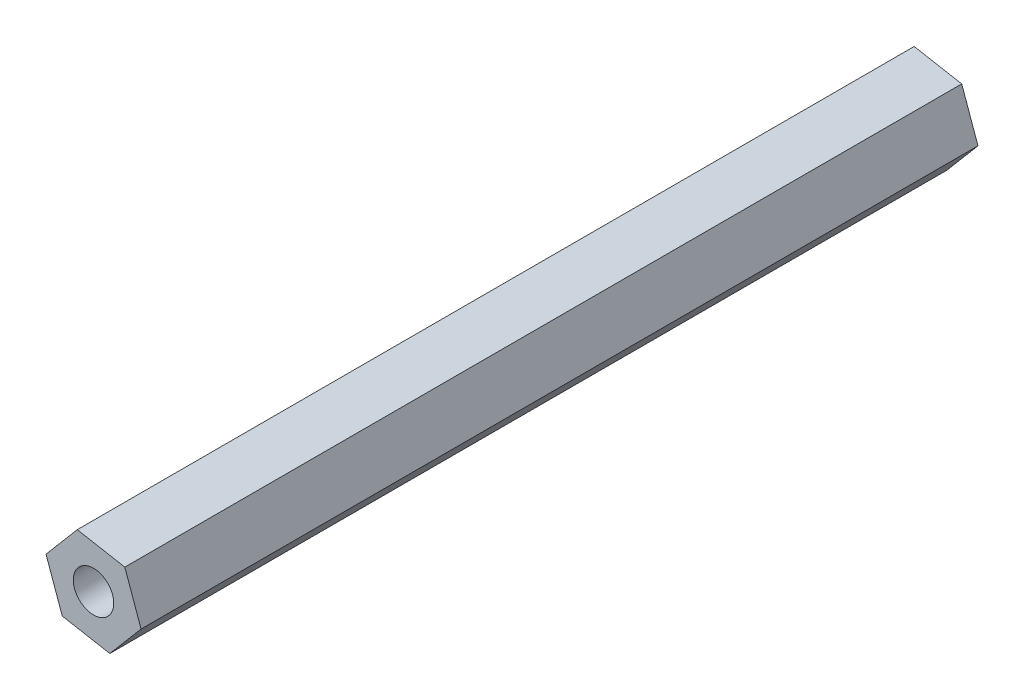
from build123d import *

# Parameters (mm, degrees)
RESSALTO_EXTRUS_O1_DEPTH = 60
ESBO_O4_R                = 1.45
CORTE_EXTRUS_O2_DEPTH    = 61


with BuildPart() as part:
    # Esboço1 → Ressalto-extrusão1 (new body)
    with BuildSketch(Plane.XY):
        Polygon((12.933175524, -4.143885809), (9.525050306, -3.523658029), (7.283854683, -6.165067156), (8.450784277, -9.426704064), (11.858909495, -10.046931845), (14.100105118, -7.405522718), align=None)
    extrude(amount=RESSALTO_EXTRUS_O1_DEPTH)

    # Esboço4 → Corte-extrusão2 (cut, through all)
    with BuildSketch(Plane(origin=(0, 0, 0), x_dir=(-1, 0, 0), z_dir=(0, 0, -1))):
        with Locations((-10.691979901, -6.785294937)):
            Circle(ESBO_O4_R)
    extrude(amount=-CORTE_EXTRUS_O2_DEPTH, mode=Mode.SUBTRACT)


solid = part.part
